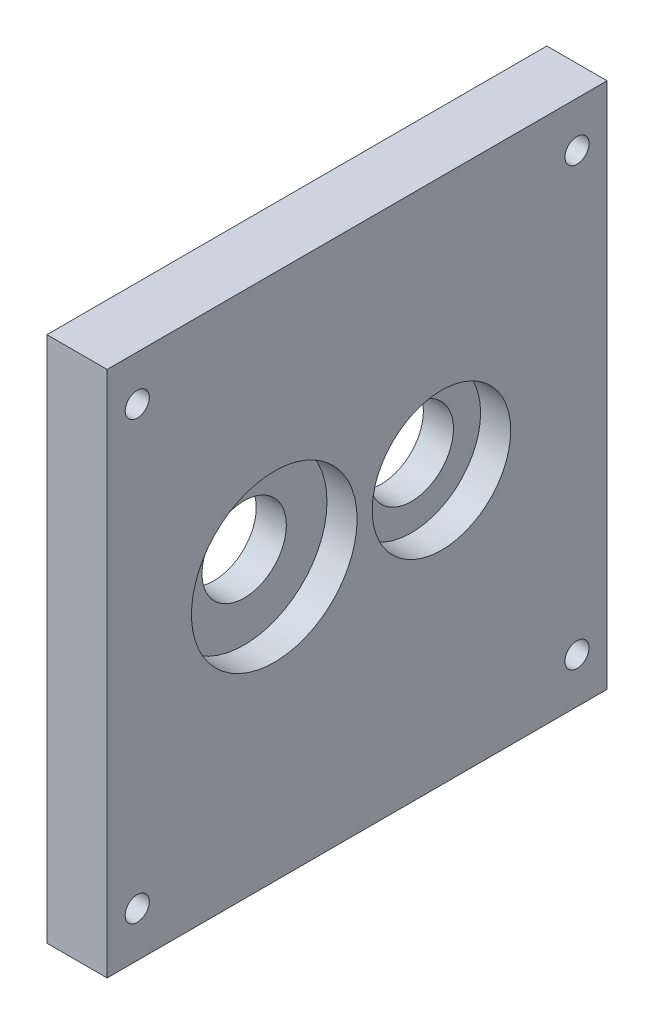
from build123d import *

# Parameters (mm, degrees)
SKETCH1_W           = 20
SKETCH1_H           = 166
BOSS_EXTRUDE1_DEPTH = 175
SKETCH2_R           = 14
CUT_EXTRUDE1_DEPTH  = 175
SKETCH3_R           = 27.5
SKETCH3_R_2         = 23
CUT_EXTRUDE2_DEPTH  = 10
SKETCH4_R           = 4
CUT_EXTRUDE3_DEPTH  = 21


with BuildPart() as part:
    # Sketch1 → Boss-Extrude1 (new body)
    with BuildSketch(Plane(origin=(0, 0, 0), x_dir=(1, 0, 0), z_dir=(0, 1, 0))):
        Rectangle(SKETCH1_W, SKETCH1_H)
    extrude(amount=BOSS_EXTRUDE1_DEPTH)

    # Sketch2 → Cut-Extrude1 (cut)
    with BuildSketch(Plane(origin=(10, 0, 0), x_dir=(0, 0, -1), z_dir=(1, 0, 0))):
        with Locations((-27.5, 90.5)):
            Circle(SKETCH2_R)
        with Locations((28, 90.5)):
            Circle(SKETCH2_R)
    extrude(amount=-CUT_EXTRUDE1_DEPTH, mode=Mode.SUBTRACT)

    # Sketch3 → Cut-Extrude2 (cut)
    with BuildSketch(Plane(origin=(10, 0, 0), x_dir=(0, 0, -1), z_dir=(1, 0, 0))):
        with Locations((-27.5, 90.5)):
            Circle(SKETCH3_R)
        with Locations((28, 90.5)):
            Circle(SKETCH3_R_2)
    extrude(amount=-CUT_EXTRUDE2_DEPTH, mode=Mode.SUBTRACT)

    # Sketch4 → Cut-Extrude3 (cut, through all)
    with BuildSketch(Plane(origin=(10, 0, 0), x_dir=(0, 0, -1), z_dir=(1, 0, 0))):
        with Locations((73, 160)):
            Circle(SKETCH4_R)
        with Locations((73, 15)):
            Circle(SKETCH4_R)
        with Locations((-73, 15)):
            Circle(SKETCH4_R)
        with Locations((-73, 160)):
            Circle(SKETCH4_R)
    extrude(amount=-CUT_EXTRUDE3_DEPTH, mode=Mode.SUBTRACT)


solid = part.part
